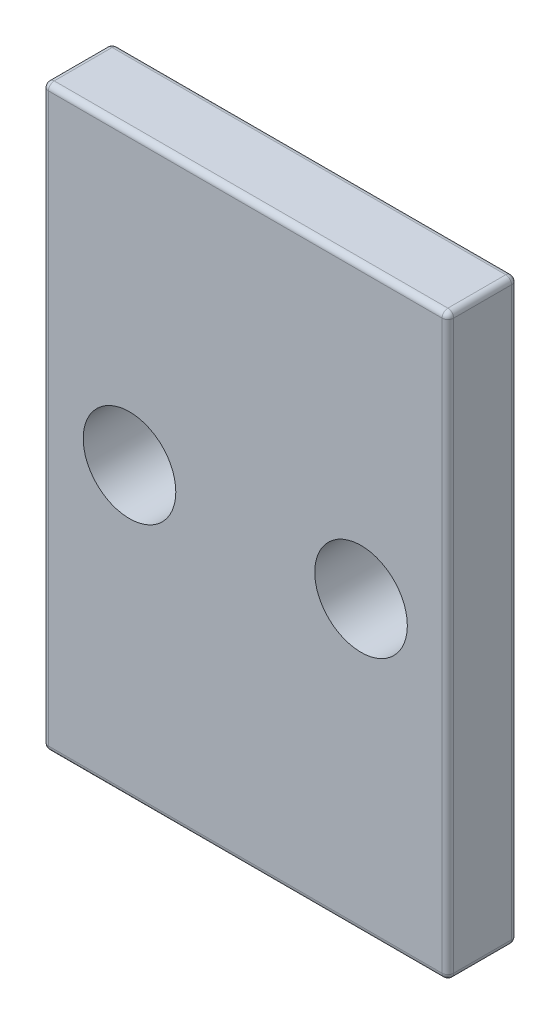
from build123d import *

# Parameters (mm, degrees)
SKETCH1_W           = 35
SKETCH1_H           = 50
SKETCH1_R           = 4
BOSS_EXTRUDE1_DEPTH = 6
FILLET1_R           = 0.5


with BuildPart() as part:
    # Sketch1 → Boss-Extrude1 (new body)
    with BuildSketch(Plane.XY):
        Rectangle(SKETCH1_W, SKETCH1_H)
        with Locations((-10, 0)):
            Circle(SKETCH1_R, mode=Mode.SUBTRACT)
        with Locations((10, 0)):
            Circle(SKETCH1_R, mode=Mode.SUBTRACT)
    extrude(amount=BOSS_EXTRUDE1_DEPTH)

    # Fillet1
    fillet1_edges = [part.edges().sort_by_distance(p)[0] for p in [
        (-17.5, 0, 6),
        (0, -25, 6),
        (17.5, 0, 6),
        (0, -25, 0),
        (-17.5, 0, 0),
        (0, 25, 0),
        (17.5, 0, 0),
        (17.5, -25, 3),
        (-17.5, -25, 3),
        (-17.5, 25, 3),
        (17.5, 25, 3),
        (0, 25, 6),
    ]]
    fillet(fillet1_edges, radius=FILLET1_R)


solid = part.part
